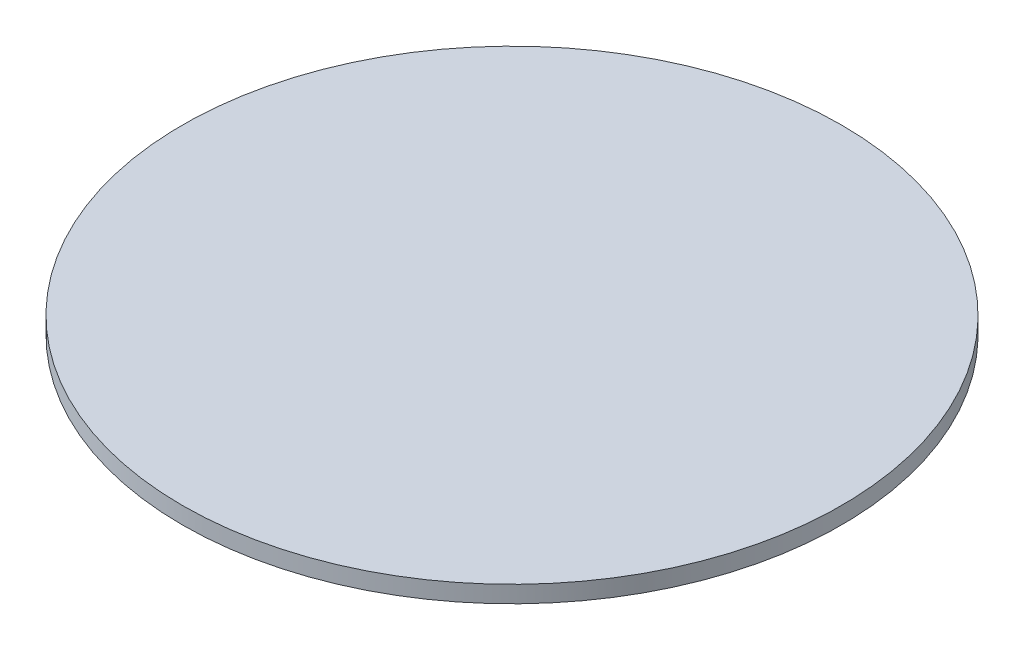
from build123d import *

# Parameters (mm, degrees)
SKETCH1_R           = 19.5
BOSS_EXTRUDE1_DEPTH = 1


with BuildPart() as part:
    # Sketch1 → Boss-Extrude1 (new body)
    with BuildSketch(Plane(origin=(0, 0, 0), x_dir=(1, 0, 0), z_dir=(0, 1, 0))):
        Circle(SKETCH1_R)
    extrude(amount=BOSS_EXTRUDE1_DEPTH)


solid = part.part
